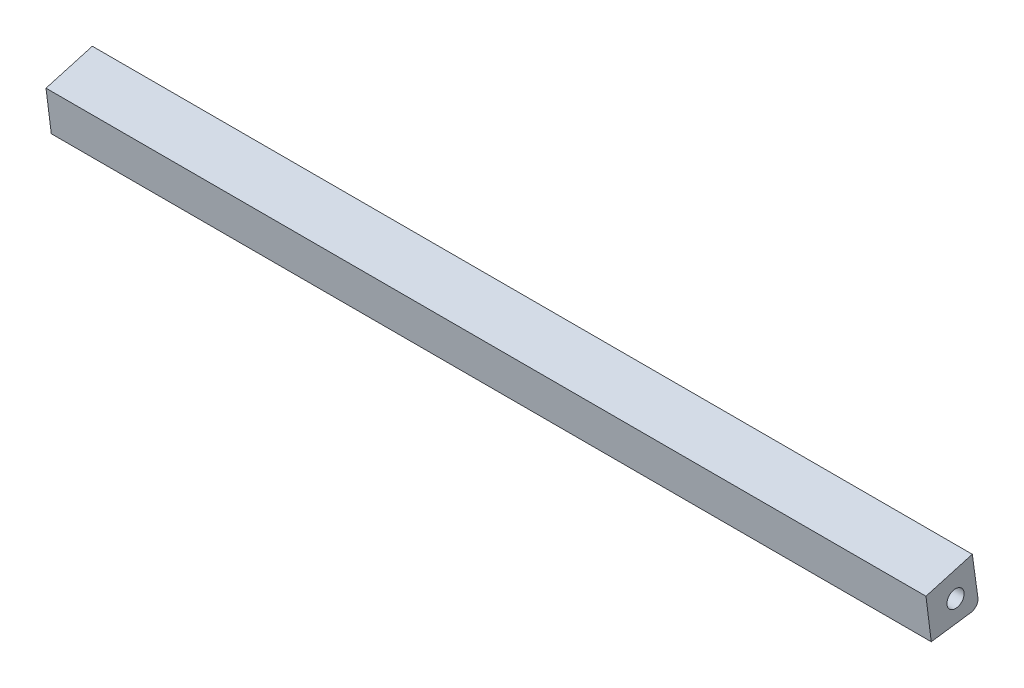
from build123d import *

# Parameters (mm, degrees)
SKETCH1_R           = 2.1
BOSS_EXTRUDE1_DEPTH = 215
FILLET1_R           = 2


with BuildPart() as part:
    # Sketch1 → Boss-Extrude1 (new body)
    with BuildSketch(Plane(origin=(0, 0, 0), x_dir=(0, 0, -1), z_dir=(1, 0, 0))):
        Polygon((87.447995492, 61.569861664), (99.124438977, 63.188614895), (97.476589763, 75.074934467), (86.155762657, 71.861000707), align=None)
        with Locations((93.379181481, 67.734629599)):
            Circle(SKETCH1_R, mode=Mode.SUBTRACT)
    extrude(amount=BOSS_EXTRUDE1_DEPTH)

    # Fillet1
    fillet1_edges = [part.edges().sort_by_distance(p)[0] for p in [
        (107.5, 63.188614895, -99.124438977),
    ]]
    fillet(fillet1_edges, radius=FILLET1_R)


solid = part.part
